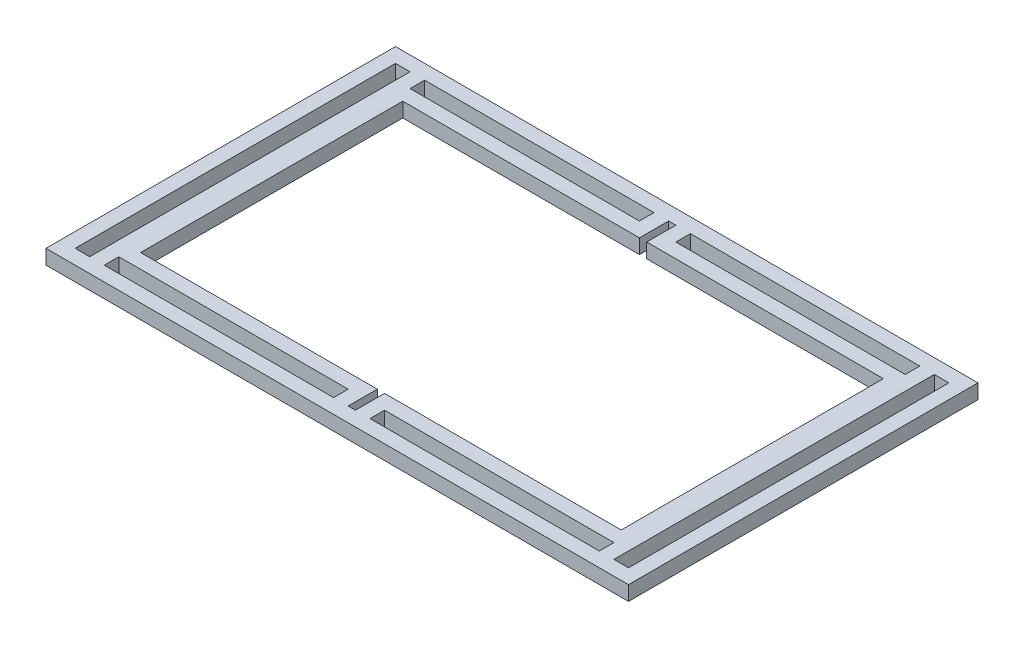
from build123d import *

# Parameters (mm, degrees)
SKETCH1_W               = 254
SKETCH1_H               = 152.4
SKETCH1_W_2             = 6.35
SKETCH1_H_2             = 139.7
SKETCH1_W_3             = 3.175
SKETCH1_W_4             = 100.0125
SKETCH1_H_3             = 6.34492
BOSS_EXTRUDE1_DEPTH     = 6.35
SKETCH2_W               = 209.55
SKETCH2_H               = 114.3
CUT_EXTRUDE1_DEPTH      = 65.278
CUT_EXTRUDE1_DEPTH_BACK = 127


with BuildPart() as part:
    # Sketch1 → Boss-Extrude1 (new body)
    with BuildSketch(Plane(origin=(0, 0, 0), x_dir=(1, 0, 0), z_dir=(0, 1, 0))):
        Rectangle(SKETCH1_W, SKETCH1_H)
        with Locations((117.475, 0)):
            Rectangle(SKETCH1_W_2, SKETCH1_H_2, mode=Mode.SUBTRACT)
        Rectangle(SKETCH1_W_3, SKETCH1_H_2, mode=Mode.SUBTRACT)
        with Locations((-117.475, 0)):
            Rectangle(SKETCH1_W_2, SKETCH1_H_2, mode=Mode.SUBTRACT)
        with Locations((-57.94375, 66.67754)):
            Rectangle(SKETCH1_W_4, SKETCH1_H_3, mode=Mode.SUBTRACT)
        with Locations((57.94375, -66.68262)):
            Rectangle(SKETCH1_W_4, SKETCH1_H_3, mode=Mode.SUBTRACT)
        with Locations((57.94375, 66.67754)):
            Rectangle(SKETCH1_W_4, SKETCH1_H_3, mode=Mode.SUBTRACT)
        with Locations((-57.94375, -66.67754)):
            Rectangle(SKETCH1_W_4, SKETCH1_H_3, mode=Mode.SUBTRACT)
    extrude(amount=BOSS_EXTRUDE1_DEPTH)

    # Sketch2 → Cut-Extrude1 (cut, two sides)
    with BuildSketch(Plane(origin=(0, 0, 0), x_dir=(1, 0, 0), z_dir=(0, 1, 0))) as cut_extrude1_sk:
        Rectangle(SKETCH2_W, SKETCH2_H)
    extrude(amount=CUT_EXTRUDE1_DEPTH, mode=Mode.SUBTRACT)
    extrude(cut_extrude1_sk.sketch, amount=-CUT_EXTRUDE1_DEPTH_BACK, mode=Mode.SUBTRACT)


solid = part.part
